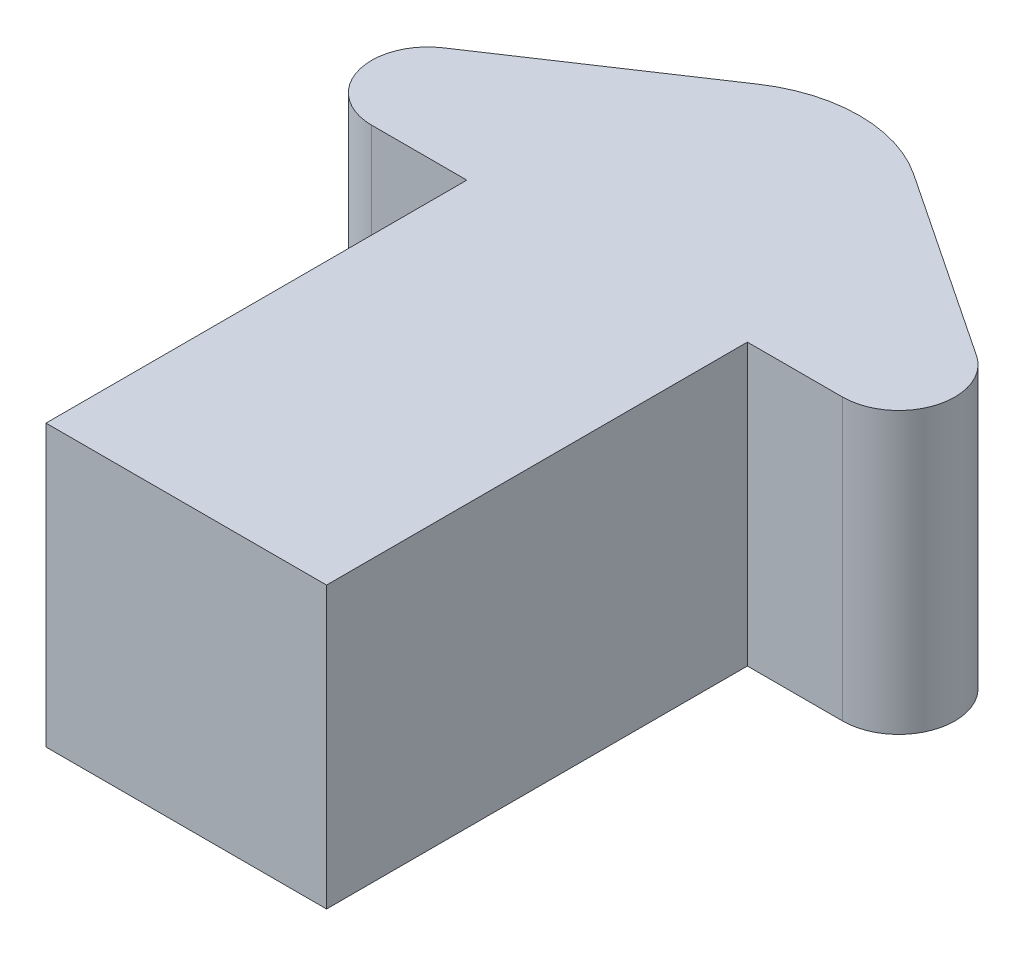
from build123d import *

# Parameters (mm, degrees)
SKETCH1_W           = 10
SKETCH1_H           = 15
BOSS_EXTRUDE1_DEPTH = 10
FILLET1_R           = 2
FILLET2_R           = 5


with BuildPart() as part:
    # Sketch1 → Boss-Extrude1 (new body)
    with BuildSketch(Plane(origin=(0, 0, 0), x_dir=(1, 0, 0), z_dir=(0, 1, 0))):
        with Locations((4.913793103, 7.456896552)):
            Rectangle(SKETCH1_W, SKETCH1_H)
        Polygon((19.913793103, 14.956896552), (4.913793103, 24.956896552), (4.913793103, 14.956896552), (9.913793103, 14.956896552), align=None)
        Polygon((4.913793103, 24.956896552), (-10.086206897, 14.956896552), (-0.086206897, 14.956896552), (4.913793103, 14.956896552), align=None)
    extrude(amount=BOSS_EXTRUDE1_DEPTH)

    # Fillet1
    fillet1_edges = [part.edges().sort_by_distance(p)[0] for p in [
        (-10.086206897, 5, -14.956896552),
        (19.913793103, 5, -14.956896552),
    ]]
    fillet(fillet1_edges, radius=FILLET1_R)

    # Fillet2
    fillet2_edges = [part.edges().sort_by_distance(p)[0] for p in [
        (4.913793103, 5, -24.956896552),
    ]]
    fillet(fillet2_edges, radius=FILLET2_R)


solid = part.part
